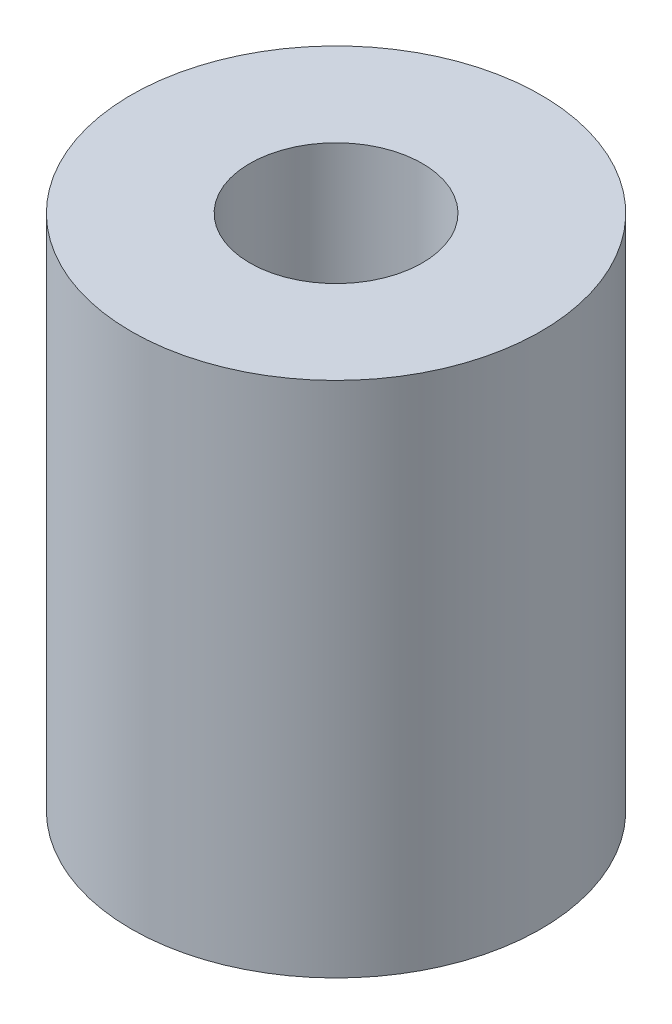
from build123d import *

# Parameters (mm, degrees)
SKETCH1_R           = 9.5
BOSS_EXTRUDE1_DEPTH = 24
SKETCH2_R           = 4
CUT_EXTRUDE1_DEPTH  = 12
SKETCH3_R           = 2.5
CUT_EXTRUDE2_DEPTH  = 12


with BuildPart() as part:
    # Sketch1 → Boss-Extrude1 (new body)
    with BuildSketch(Plane(origin=(0, 0, 0), x_dir=(1, 0, 0), z_dir=(0, 1, 0))):
        Circle(SKETCH1_R)
    extrude(amount=BOSS_EXTRUDE1_DEPTH)

    # Sketch2 → Cut-Extrude1 (cut)
    with BuildSketch(Plane(origin=(0, 24, 0), x_dir=(1, 0, 0), z_dir=(0, 1, 0))):
        Circle(SKETCH2_R)
    extrude(amount=-CUT_EXTRUDE1_DEPTH, mode=Mode.SUBTRACT)

    # Sketch3 → Cut-Extrude2 (cut)
    with BuildSketch(Plane.XZ):
        Circle(SKETCH3_R)
    extrude(amount=-CUT_EXTRUDE2_DEPTH, mode=Mode.SUBTRACT)


solid = part.part
